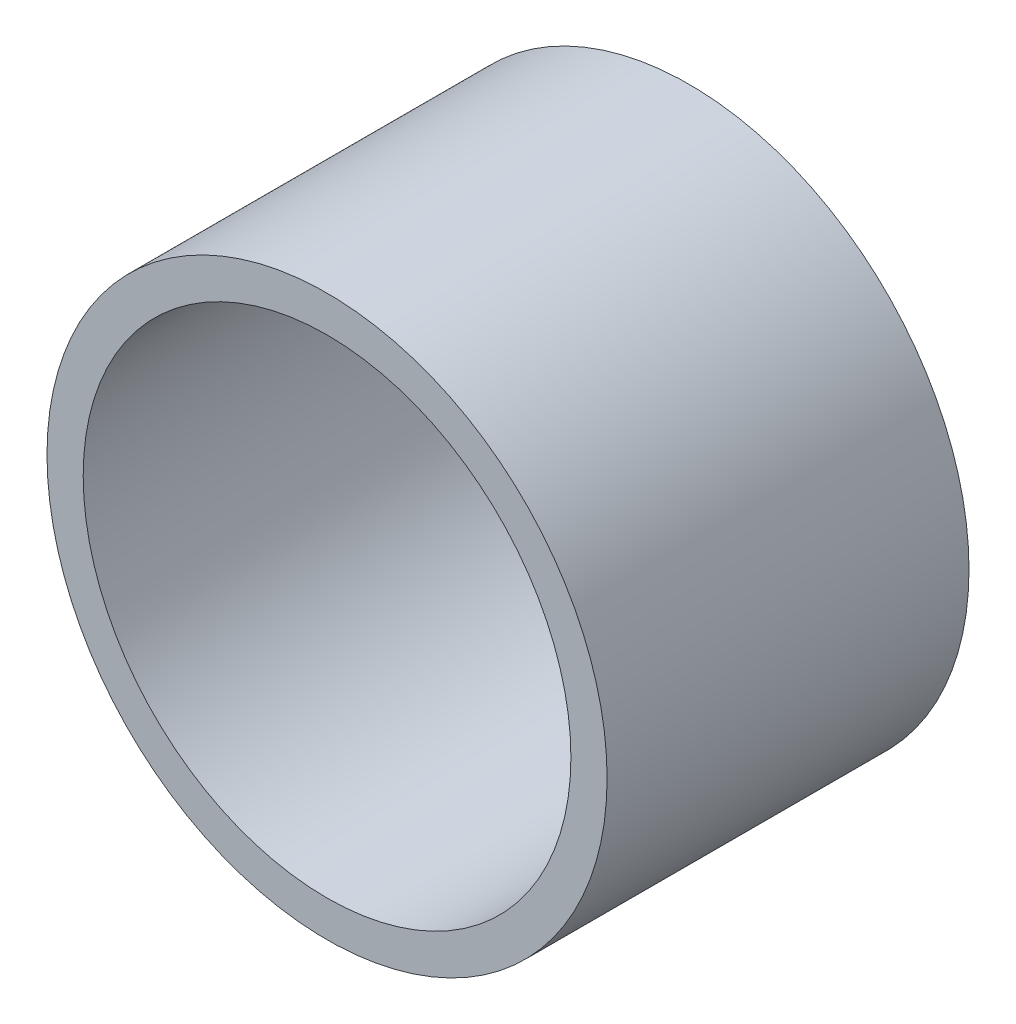
from build123d import *

# Parameters (mm, degrees)
SKETCH1_R      = 9.827479793
SKETCH1_R_2    = 8.557479793
EXTRUDE1_DEPTH = 12.7


with BuildPart() as part:
    # Sketch1 → Extrude1 (new body)
    with BuildSketch(Plane.XY):
        Circle(SKETCH1_R)
        Circle(SKETCH1_R_2, mode=Mode.SUBTRACT)
    extrude(amount=EXTRUDE1_DEPTH)


solid = part.part
